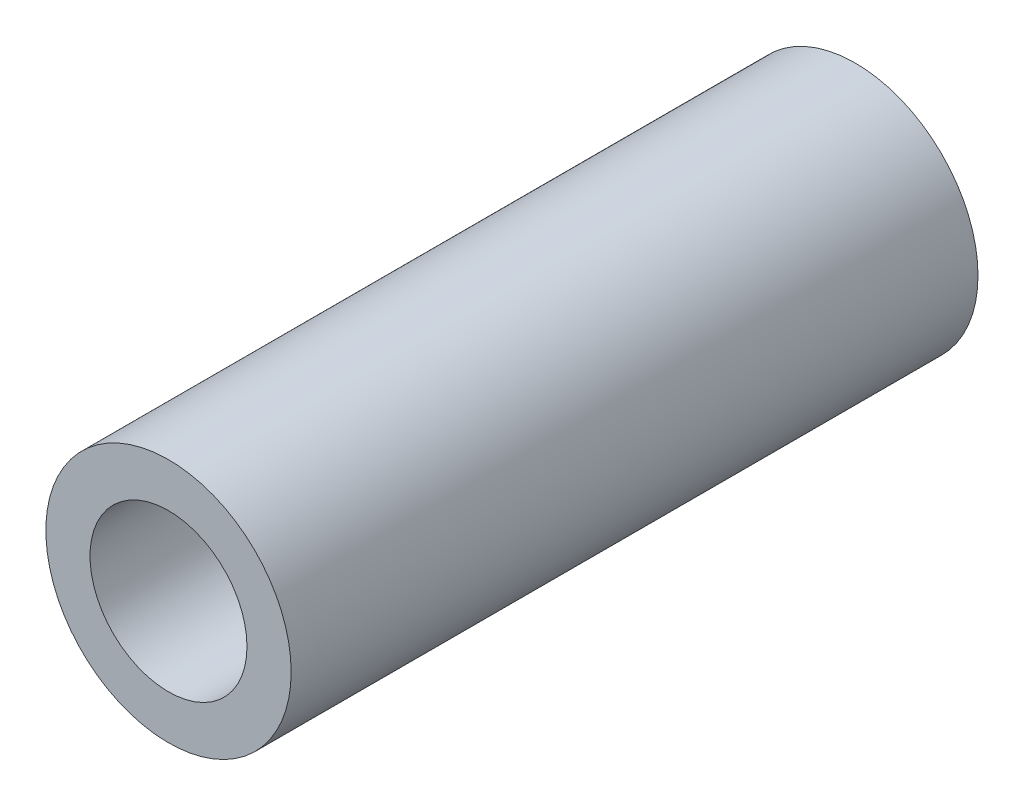
from build123d import *

# Parameters (mm, degrees)
SKETCH_1_R      = 2.5
SKETCH_1_R_2    = 1.6
EXTRUDE_1_DEPTH = 14


with BuildPart() as part:
    # 草图1 → 凸台-拉伸1 (new body)
    with BuildSketch(Plane.XY):
        Circle(SKETCH_1_R)
        Circle(SKETCH_1_R_2, mode=Mode.SUBTRACT)
    extrude(amount=EXTRUDE_1_DEPTH)


solid = part.part
